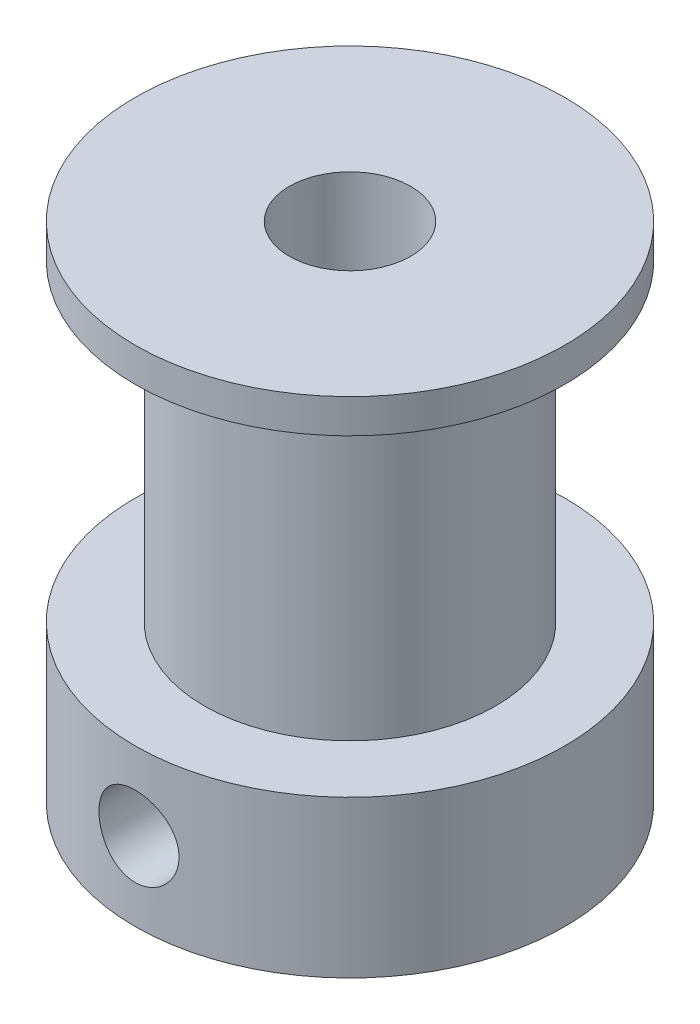
from build123d import *

# Parameters (mm, degrees)
CROQUIS3_W     = 1.65
CROQUIS3_H     = 8.851
MATRIZC1_COUNT = 2
MATRIZC1_ANGLE = 90


with BuildPart() as part:
    # Croquis1 → Revolución1 (revolve)
    with BuildSketch(Plane.XY):
        Polygon((8.85, 6.45), (8.85, 0), (2.5, 0), (2.5, 20.75), (8.85, 20.75), (8.85, 19.35), (6, 19.35), (6, 6.45), align=None)
    revolve(axis=Axis((0, 0, 0), (0, 1, 0)))

    # Croquis3 → Taladro roscado M41 (revolve, cut)
    with BuildSketch(Plane(origin=(0, 3.225, 0), x_dir=(0, 1, 0), z_dir=(1, 0, 0))):
        with Locations((0.825, 4.4255)):
            Rectangle(CROQUIS3_W, CROQUIS3_H)
    taladro_roscado_m41 = revolve(axis=Axis((0, 3.225, -6.35), (0, 0, 1)), mode=Mode.SUBTRACT)

    # MatrizC1: Taladro roscado M41 ×2 about axis
    matrizc1_axis = Axis((0, 0, 0), (0, -1, 0))
    for i in range(1, MATRIZC1_COUNT):
        add(taladro_roscado_m41.rotate(matrizc1_axis, i * MATRIZC1_ANGLE / (MATRIZC1_COUNT - 1)), mode=Mode.SUBTRACT)


solid = part.part
